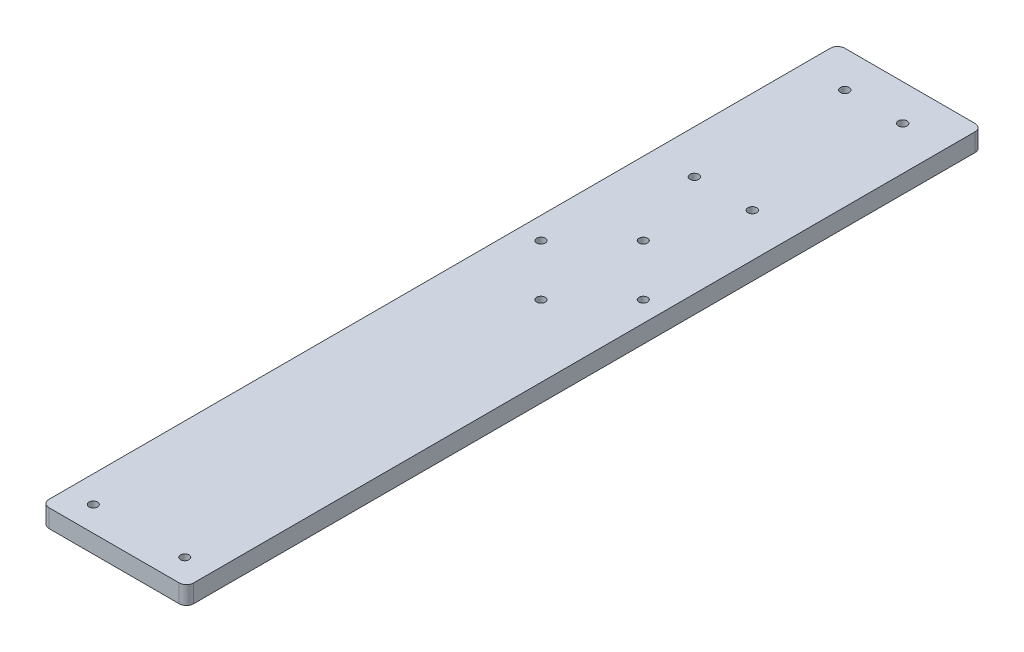
from build123d import *

# Parameters (mm, degrees)
BOSS_EXTRUDE1_DEPTH = 6.35
SKETCH2_R           = 1.5
CUT_EXTRUDE1_DEPTH  = 6.35
SKETCH3_R           = 1.55
CUT_EXTRUDE2_DEPTH  = 6.35


with BuildPart() as part:
    # Sketch1 → Boss-Extrude1 (new body)
    with BuildSketch(Plane(origin=(0, 0, 0), x_dir=(1, 0, 0), z_dir=(0, 1, 0))):
        with BuildLine():
            Line((2.54, 0), (48.26, 0))
            ThreePointArc((48.26, 0), (50.056051224, 0.743948776), (50.8, 2.54))
            Line((50.8, 2.54), (50.8, 276.86))
            ThreePointArc((50.8, 276.86), (50.056051224, 278.656051224), (48.26, 279.4))
            Line((48.26, 279.4), (2.54, 279.4))
            ThreePointArc((2.54, 279.4), (0.743948776, 278.656051224), (0, 276.86))
            Line((0, 276.86), (0, 2.54))
            ThreePointArc((0, 2.54), (0.743948776, 0.743948776), (2.54, 0))
        make_face()
    extrude(amount=BOSS_EXTRUDE1_DEPTH)

    # Sketch2 → Cut-Extrude1 (cut)
    with BuildSketch(Plane.XZ):
        with Locations((25.662087977, -185.525)):
            Circle(SKETCH2_R)
        with Locations((43.622600219, -167.564487758)):
            Circle(SKETCH2_R)
        with Locations((7.701575735, -167.564487758)):
            Circle(SKETCH2_R)
        with Locations((25.662087977, -149.603975516)):
            Circle(SKETCH2_R)
        with Locations((41.45, -8.758487194)):
            Circle(SKETCH2_R)
        with Locations((9.35, -8.758487194)):
            Circle(SKETCH2_R)
    extrude(amount=-CUT_EXTRUDE1_DEPTH, mode=Mode.SUBTRACT)

    # Sketch3 → Cut-Extrude2 (cut)
    with BuildSketch(Plane.XZ):
        with Locations((15.24, -266.7)):
            Circle(SKETCH3_R)
        with Locations((35.56, -266.7)):
            Circle(SKETCH3_R)
        with Locations((15.24, -213.9)):
            Circle(SKETCH3_R)
        with Locations((35.56, -213.9)):
            Circle(SKETCH3_R)
    extrude(amount=-CUT_EXTRUDE2_DEPTH, mode=Mode.SUBTRACT)


solid = part.part
